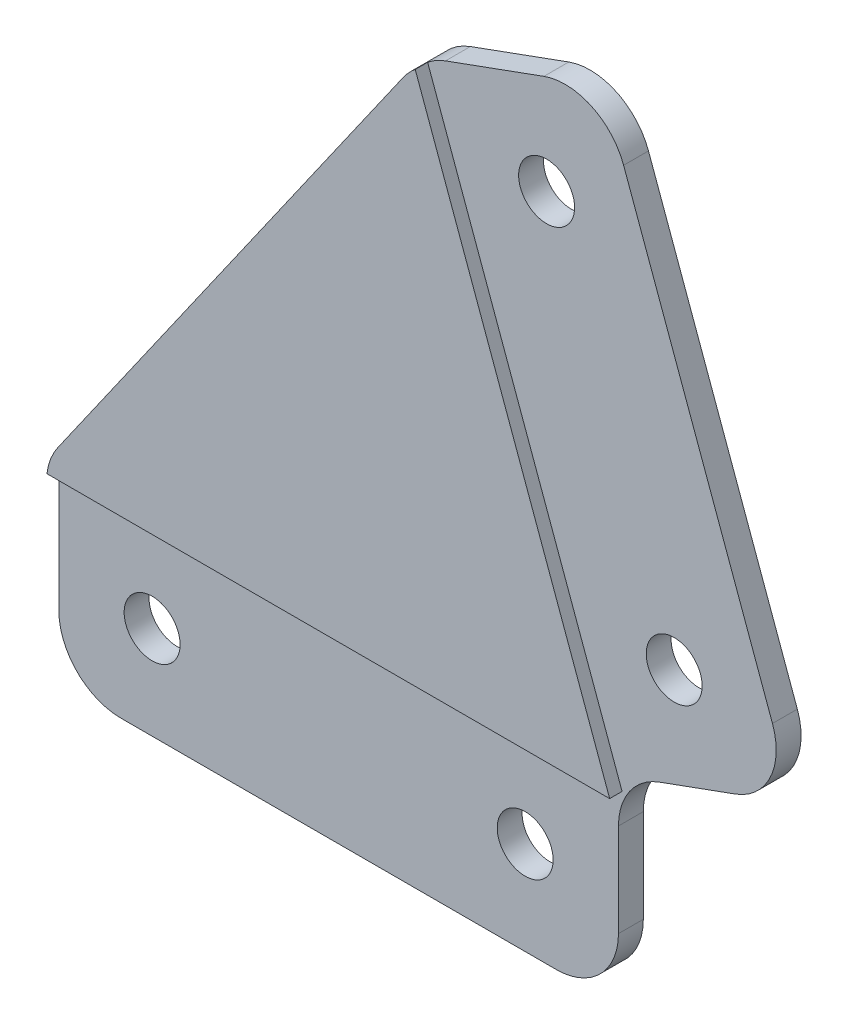
from build123d import *

# Parameters (mm, degrees)
EXTRUDE_1_DEPTH     = 3
SKETCH_2_R          = 2.25
CUT_EXTRUDE_1_DEPTH = 3
FILLET_1_R          = 5
CUT_EXTRUDE_2_DEPTH = 1


with BuildPart() as part:
    # ｽｹｯﾁ1 → ﾎﾞｽ - 押し出し1 (new body)
    with BuildSketch(Plane.XY):
        Polygon((440, 0), (440, -16), (395, -16), (395, 0), (424.60909355, 42.286167935), (438.704482862, 47.416470085), (454.095389312, 5.13030215), align=None)
    extrude(amount=EXTRUDE_1_DEPTH)

    # ｽｹｯﾁ2 → ｶｯﾄ - 押し出し1 (cut)
    with BuildSketch(Plane.XY.offset(3)):
        with Locations((402.5, -8.5)):
            Circle(SKETCH_2_R)
        with Locations((432.5, -8.5)):
            Circle(SKETCH_2_R)
        with Locations((434.221939281, 37.803624354)):
            Circle(SKETCH_2_R)
        with Locations((444.482543581, 9.612845731)):
            Circle(SKETCH_2_R)
    extrude(amount=-CUT_EXTRUDE_1_DEPTH, mode=Mode.SUBTRACT)

    # ﾌｨﾚｯﾄ1
    fillet_1_edges = [part.edges().sort_by_distance(p)[0] for p in [
        (395, -16, 1.5),
        (395, 0, 1.5),
        (424.60909355, 42.286167935, 1.5),
        (438.704482862, 47.416470085, 1.5),
        (454.095389312, 5.13030215, 1.5),
        (440, 0, 1.5),
        (440, -16, 1.5),
    ]]
    fillet(fillet_1_edges, radius=FILLET_1_R)

    # ｽｹｯﾁ4 → ｶｯﾄ - 押し出し2 (cut)
    with BuildSketch(Plane.XY.offset(3)):
        Polygon((438.704482862, 47.416470085), (455.121449742, 2.311224288), (443, -2.100622615), (443, -16), (395, -16), (395, -0.95), (440.292562834, -0.95), (424.562108919, 42.269066928), align=None)
    extrude(amount=-CUT_EXTRUDE_2_DEPTH, mode=Mode.SUBTRACT)


solid = part.part
